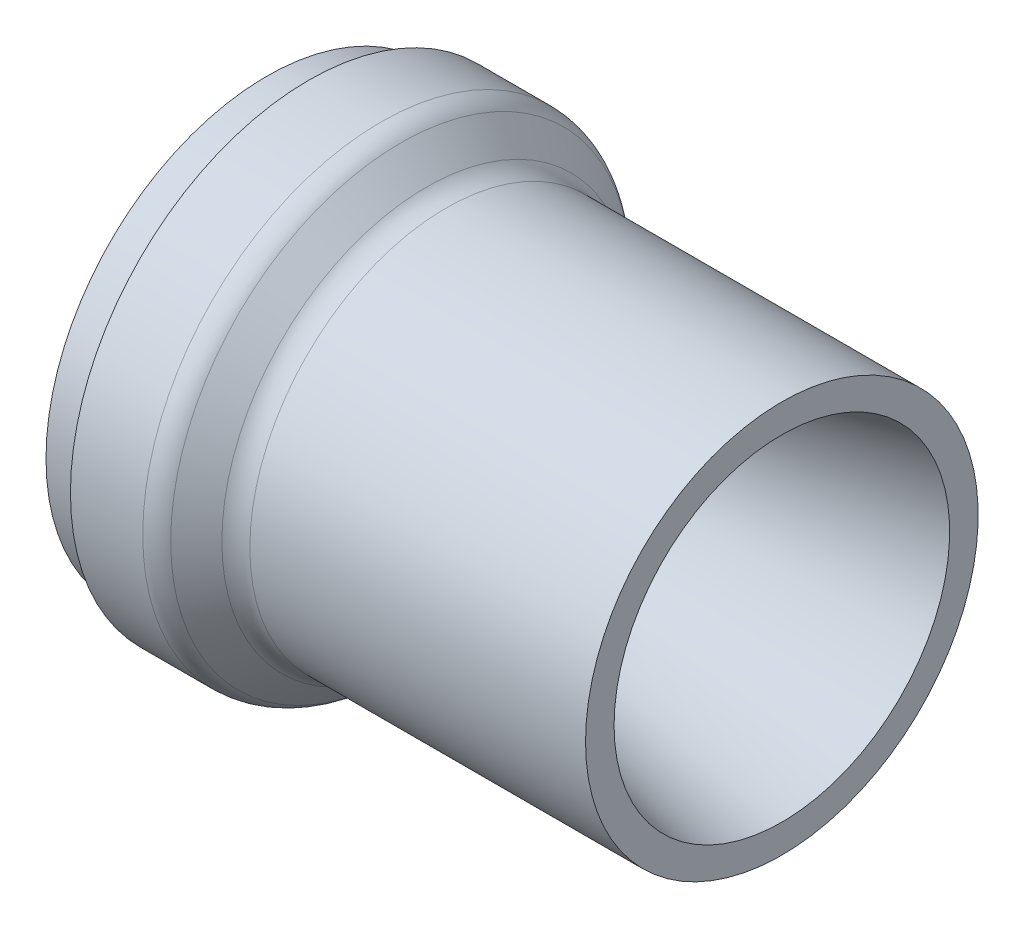
from build123d import *


with BuildPart() as part:
    # Sketch1 → Revolve1 (revolve)
    with BuildSketch(Plane.XY):
        with BuildLine():
            Line((116.957401038, 12.446), (21.359317213, 32.766))
            Line((21.359317213, 32.766), (15.009317213, 32.766))
            Line((15.009317213, 32.766), (0, 6.7691))
            Line((0, 6.7691), (0, 0.4191))
            Line((0, 0.4191), (9.525, 0.4191))
            Line((9.525, 0.4191), (9.525, -3.556))
            Line((9.525, -3.556), (25.944743879, -3.556))
            ThreePointArc((25.944743879, -3.556), (28.374783674, -3.072635031), (30.434871939, -1.696128061))
            Line((30.434871939, -1.696128061), (36.240128061, 4.109128061))
            ThreePointArc((36.240128061, 4.109128061), (38.300216326, 5.485635031), (40.730256121, 5.969))
            Line((40.730256121, 5.969), (116.957401038, 5.969))
            Line((116.957401038, 5.969), (116.957401038, 12.446))
        make_face()
    revolve(axis=Axis((0, 50.546, 0), (1, 0, 0)))


solid = part.part
